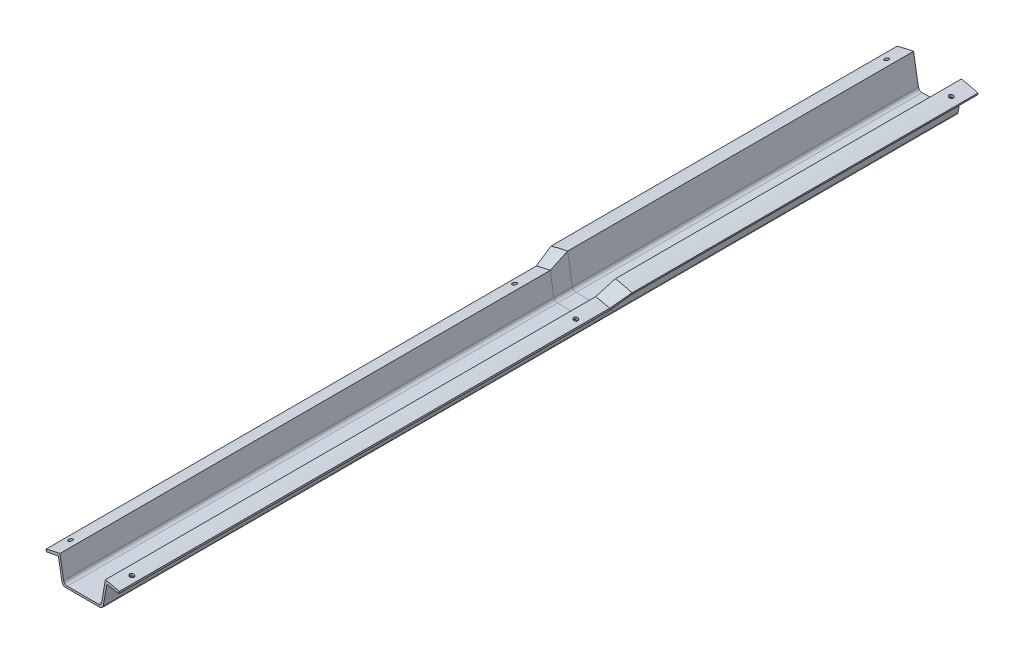
from build123d import *

# Parameters (mm, degrees)
BOSS_EXTRUDE1_DEPTH       = 237.49
BOSS_EXTRUDE2_DEPTH       = 336.55
FILLET1_R                 = 2.54
FILLET2_R                 = 2.54
F_4_CLEARANCE_HOLE3_D     = 2.9464
F_4_CLEARANCE_HOLE3_DEPTH = 25.4
F_4_CLEARANCE_HOLE3_TIP   = 0.885187864
F_4_CLEARANCE_HOLE4_D     = 2.9464
F_4_CLEARANCE_HOLE4_DEPTH = 25.4
F_4_CLEARANCE_HOLE4_TIP   = 0.885187864
F_4_CLEARANCE_HOLE5_D     = 2.9464
F_4_CLEARANCE_HOLE5_DEPTH = 12.7
F_4_CLEARANCE_HOLE5_TIP   = 0.885187864
F_4_CLEARANCE_HOLE6_D     = 2.9464
F_4_CLEARANCE_HOLE6_DEPTH = 12.7
F_4_CLEARANCE_HOLE6_TIP   = 0.885187864


with BuildPart() as part:
    # 3DSketch1 for Loft2 → Loft2 section 0
    with BuildSketch(Plane(origin=(25.14093528, 88.576176245, 12.7), x_dir=(-0.2730484418088959, -0.9620002850445181, 0), z_dir=(0, 0, -1))):
        with BuildLine():
            Line((0, 0), (1.514242104, -0.172182612))
            Line((1.514242104, -0.172182612), (2.214491758, 8.20179449))
            Line((2.214491758, 8.20179449), (18.60742462, 6.462791205))
            Line((18.60742462, 6.462791205), (26.167043779, 33.096731096))
            Line((26.167043779, 33.096731096), (11.304898639, 40.22898334))
            Line((11.304898639, 40.22898334), (15.108293839, 47.722182058))
            Line((15.108293839, 47.722182058), (13.729386407, 48.37117381))
            # circular arc as an exact rational Bezier (weights 1, cos(half-angle), 1)
            Bezier((13.729386407, 48.37117381), (11.15915023, 44.208224795), (9.044543669, 39.796343381), weights=[1, 0.998591281, 1])
            Line((9.044543669, 39.796343381), (24.505322138, 32.380234952))
            Line((24.505322138, 32.380234952), (17.569891716, 7.945427712))
            Line((17.569891716, 7.945427712), (0.518465753, 9.757390103))
            Bezier((0.518465753, 9.757390103), (0, 4.892469572), (0, 0), weights=[1, 0.998591281, 1])
        make_face()
    # Sketch1 for Loft2 → Loft2 section 1
    with BuildSketch(Plane.XY):
        with BuildLine():
            Line((-12.7, 73.846441258), (12.7, 73.846441258))
            Line((12.7, 73.846441258), (16.413015757, 95.436441258))
            Bezier((16.413015757, 95.436441258), (22.196437798, 94.441817026), (27.817431193, 92.756088361), weights=[1, 0.998168879, 1])
            Line((27.817431193, 92.756088361), (27.416130546, 91.417967742))
            Line((27.416130546, 91.417967742), (17.403126873, 93.139989068))
            Line((17.403126873, 93.139989068), (13.843, 72.438989068))
            Line((13.843, 72.438989068), (-13.843, 72.438989068))
            Line((-13.843, 72.438989068), (-17.403126873, 93.139989068))
            Line((-17.403126873, 93.139989068), (-27.416130546, 91.417967742))
            Line((-27.416130546, 91.417967742), (-27.817431193, 92.756088361))
            Bezier((-27.817431193, 92.756088361), (-22.196437798, 94.441817026), (-16.413015757, 95.436441258), weights=[1, 0.998168879, 1])
            Line((-16.413015757, 95.436441258), (-12.7, 73.846441258))
        make_face()
    loft()

    # Sketch1_4 → Boss-Extrude1 (add)
    with BuildSketch(Plane.XY):
        with BuildLine():
            Line((-12.7, 73.846441258), (12.7, 73.846441258))
            Line((12.7, 73.846441258), (16.413015757, 95.436441258))
            ThreePointArc((16.413015757, 95.436441258), (22.155793424, 94.268882586), (27.817431193, 92.756088361))
            Line((27.817431193, 92.756088361), (27.416130546, 91.417967742))
            Line((27.416130546, 91.417967742), (17.403126873, 93.139989068))
            Line((17.403126873, 93.139989068), (13.843, 72.438989068))
            Line((13.843, 72.438989068), (-13.843, 72.438989068))
            Line((-13.843, 72.438989068), (-17.403126873, 93.139989068))
            Line((-17.403126873, 93.139989068), (-27.416130546, 91.417967742))
            Line((-27.416130546, 91.417967742), (-27.817431193, 92.756088361))
            ThreePointArc((-27.817431193, 92.756088361), (-22.155793424, 94.268882586), (-16.413015757, 95.436441258))
            Line((-16.413015757, 95.436441258), (-12.7, 73.846441258))
        make_face()
    extrude(amount=-BOSS_EXTRUDE1_DEPTH)

    # 3DSketch1_4 → Boss-Extrude2 (add)
    with BuildSketch(Plane(origin=(25.14093528, 88.576176245, 12.7), x_dir=(-0.2730484418088959, -0.9620002850445181, 0), z_dir=(0, 0, -1))):
        with BuildLine():
            Line((0, 0), (1.514242104, -0.172182612))
            Line((1.514242104, -0.172182612), (2.214491758, 8.20179449))
            Line((2.214491758, 8.20179449), (18.60742462, 6.462791205))
            Line((18.60742462, 6.462791205), (26.167043779, 33.096731096))
            Line((26.167043779, 33.096731096), (11.304898639, 40.22898334))
            Line((11.304898639, 40.22898334), (15.108293839, 47.722182058))
            Line((15.108293839, 47.722182058), (13.729386407, 48.37117381))
            ThreePointArc((13.729386407, 48.37117381), (11.273137923, 44.14594783), (9.044543669, 39.796343381))
            Line((9.044543669, 39.796343381), (24.505322138, 32.380234952))
            Line((24.505322138, 32.380234952), (17.569891716, 7.945427712))
            Line((17.569891716, 7.945427712), (0.518465753, 9.757390103))
            ThreePointArc((0.518465753, 9.757390103), (0.129707799, 4.885577457), (0, 0))
        make_face()
    extrude(amount=-BOSS_EXTRUDE2_DEPTH)

    # Fillet1
    fillet1_edges = [part.edges().sort_by_distance(p)[0] for p in [
        (-13.843, 72.438989068, -118.745),
        (-13.843, 72.439736297, 6.35),
        (13.843, 72.438989068, -118.745),
        (13.843, 72.439736297, 6.35),
        (-13.843, 72.440483526, 180.975),
        (13.843, 72.440483526, 180.975),
    ]]
    fillet(fillet1_edges, radius=FILLET1_R)

    # Fillet2
    fillet2_edges = [part.edges().sort_by_distance(p)[0] for p in [
        (-12.7, 73.846441258, -118.745),
        (-12.7, 73.844931661, 6.35),
        (12.7, 73.846441258, -118.745),
        (12.7, 73.844931661, 6.35),
        (-12.7, 73.843422063, 180.975),
        (12.7, 73.843422063, 180.975),
    ]]
    fillet(fillet2_edges, radius=FILLET2_R)

    # 4 Clearance Hole3
    with Locations(Plane(origin=(21.064518185, 89.633094885, 0), x_dir=(0.9734791733351508, -0.22877565229436342, 0), z_dir=(0.22877565229436345, 0.9734791733351509, 0))):
        with Locations((0, -336.55), (0, -31.75)):
            Hole(F_4_CLEARANCE_HOLE3_D / 2, depth=F_4_CLEARANCE_HOLE3_DEPTH)
            with Locations((0, 0, -(F_4_CLEARANCE_HOLE3_DEPTH + F_4_CLEARANCE_HOLE3_TIP / 2))):  # 118° drill point
                Cone(0, F_4_CLEARANCE_HOLE3_D / 2, F_4_CLEARANCE_HOLE3_TIP, mode=Mode.SUBTRACT)

    # 4 Clearance Hole4
    with Locations(Plane(origin=(-21.064518185, 89.633094885, 0), x_dir=(0.9734791733351509, 0.2287756522943629, 0), z_dir=(-0.2287756522943629, 0.9734791733351509, 0))):
        with Locations((0, -336.55), (0, -31.75)):
            Hole(F_4_CLEARANCE_HOLE4_D / 2, depth=F_4_CLEARANCE_HOLE4_DEPTH)
            with Locations((0, 0, -(F_4_CLEARANCE_HOLE4_DEPTH + F_4_CLEARANCE_HOLE4_TIP / 2))):  # 118° drill point
                Cone(0, F_4_CLEARANCE_HOLE4_D / 2, F_4_CLEARANCE_HOLE4_TIP, mode=Mode.SUBTRACT)

    # 4 Clearance Hole5
    with Locations(Plane(origin=(-22.154062229, 94.269289448, 0), x_dir=(0.9734791733351509, 0.2287756522943629, 0), z_dir=(-0.2287756522943629, 0.9734791733351509, 0))):
        with Locations((0, 224.79)):
            Hole(F_4_CLEARANCE_HOLE5_D / 2, depth=F_4_CLEARANCE_HOLE5_DEPTH)
            with Locations((0, 0, -(F_4_CLEARANCE_HOLE5_DEPTH + F_4_CLEARANCE_HOLE5_TIP / 2))):  # 118° drill point
                Cone(0, F_4_CLEARANCE_HOLE5_D / 2, F_4_CLEARANCE_HOLE5_TIP, mode=Mode.SUBTRACT)

    # 4 Clearance Hole6
    with Locations(Plane(origin=(22.154062229, 94.269289448, 0), x_dir=(0.9734791733351508, -0.22877565229436342, 0), z_dir=(0.22877565229436345, 0.9734791733351509, 0))):
        with Locations((0, 224.79)):
            Hole(F_4_CLEARANCE_HOLE6_D / 2, depth=F_4_CLEARANCE_HOLE6_DEPTH)
            with Locations((0, 0, -(F_4_CLEARANCE_HOLE6_DEPTH + F_4_CLEARANCE_HOLE6_TIP / 2))):  # 118° drill point
                Cone(0, F_4_CLEARANCE_HOLE6_D / 2, F_4_CLEARANCE_HOLE6_TIP, mode=Mode.SUBTRACT)


solid = part.part
